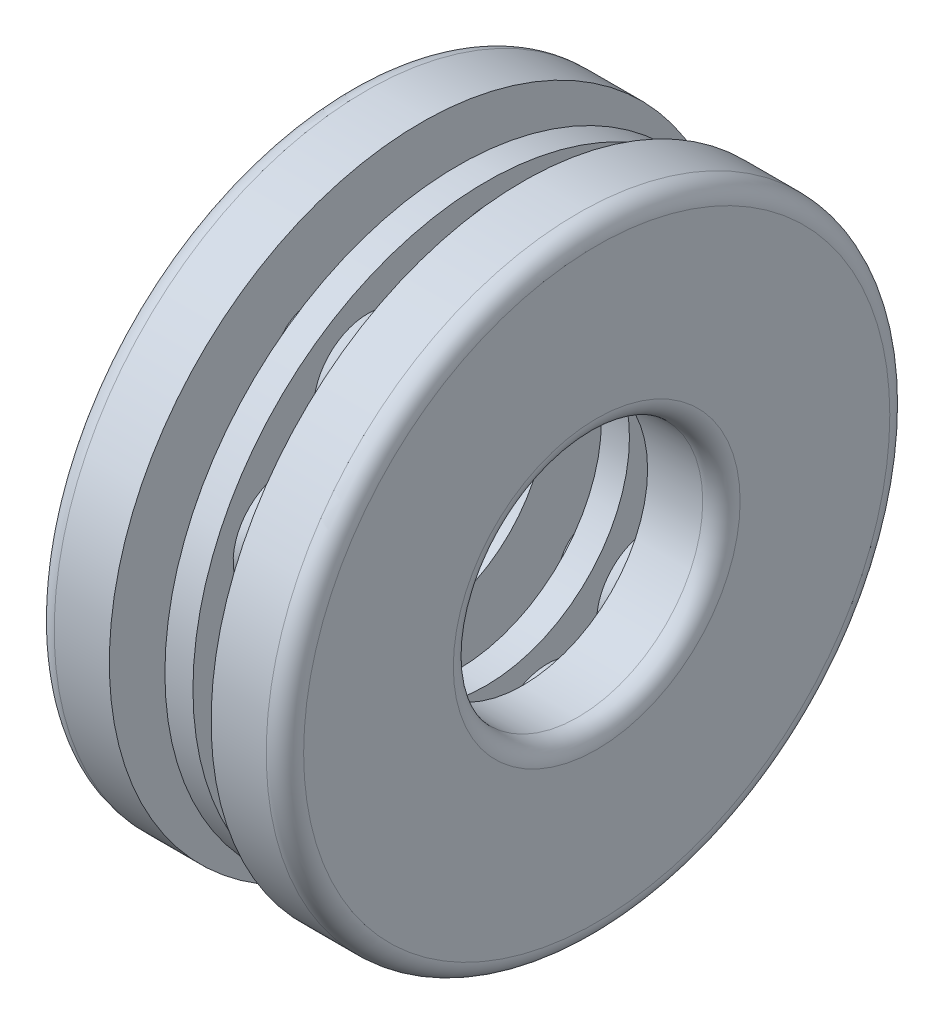
from build123d import *

# Parameters (mm, degrees)
BALLSDETAILED_COUNT = 11
CAGSPISKE_W         = 0.45
CAGSPISKE_H         = 2.4


with BuildPart() as part:
    # InnRacSke → Race (revolve)
    with BuildSketch(Plane.XY):
        with BuildLine():
            Line((-0.816, 3.184137688), (-0.816, 2))
            Line((-0.816, 2), (-1.7, 2))
            ThreePointArc((-1.7, 2), (-1.912132034, 2.087867966), (-2, 2.3))
            Line((-2, 2.3), (-2, 4.7))
            ThreePointArc((-2, 4.7), (-1.912132034, 4.912132034), (-1.7, 5))
            Line((-1.7, 5), (-0.816, 5))
            Line((-0.816, 5), (-0.816, 3.815862312))
            ThreePointArc((-0.816, 3.815862312), (-0.875, 3.5), (-0.816, 3.184137688))
        make_face()
    race = revolve(axis=Axis((-34.925, 0, 0), (1, 0, 0)))

    # BalDetSke → BallDetailed (revolve)
    with BuildSketch(Plane.XY):
        with BuildLine():
            Line((-0.9, 3.5), (0.9, 3.5))
            ThreePointArc((0.9, 3.5), (0, 2.6), (-0.9, 3.5))
        make_face()
    balldetailed = revolve(axis=Axis((-14.57325, 3.5, 0), (1, 0, 0)))

    # Mirror1: Race across plane
    add(race.mirror(Plane(origin=(0, 0, 0), x_dir=(0, 0, 1), z_dir=(1, 0, 0))))

    # BallsDetailed: BallDetailed ×11 about axis
    ballsdetailed_axis = Axis((0, 0, 0), (1, 0, 0))
    for i in range(1, BALLSDETAILED_COUNT):
        add(balldetailed.rotate(ballsdetailed_axis, i * 360 / BALLSDETAILED_COUNT))

    # CagSpiSke → CageSpine (revolve)
    with BuildSketch(Plane.XY):
        with Locations((0, 3.5)):
            Rectangle(CAGSPISKE_W, CAGSPISKE_H)
    revolve(axis=Axis((-34.925, 0, 0), (1, 0, 0)))


solid = part.part
